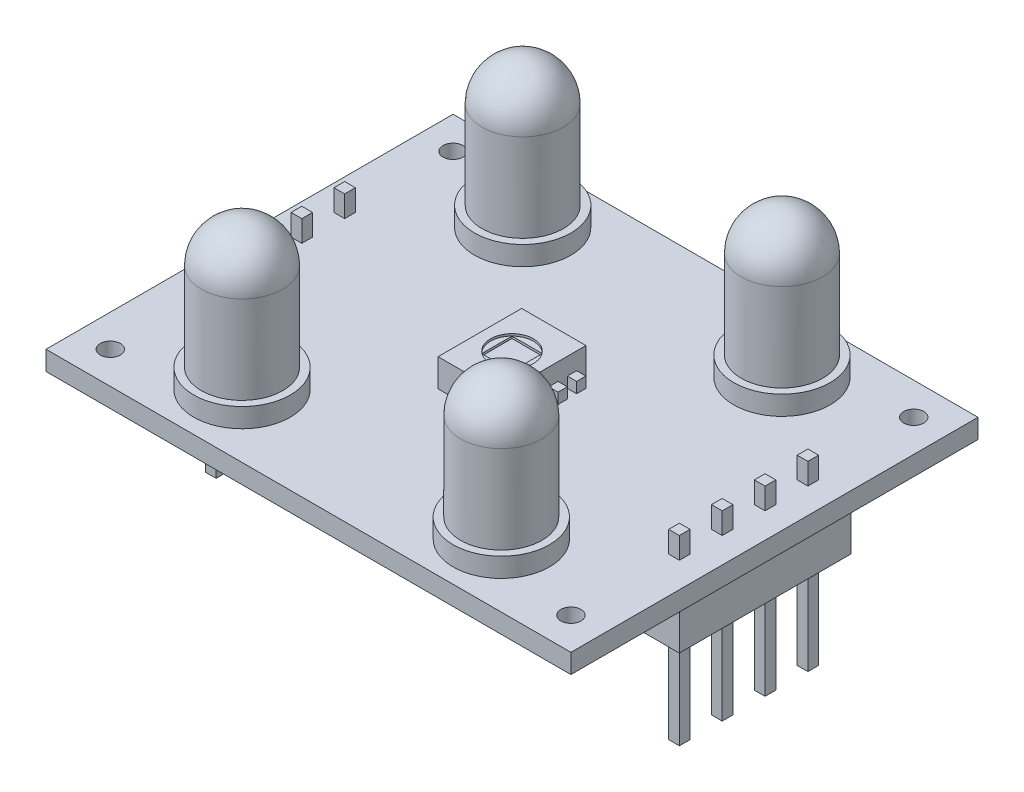
from build123d import *

# Parameters (mm, degrees)
ESQUISSE1_W                     = 31.115
ESQUISSE1_H                     = 24.13
ESQUISSE1_R                     = 0.5953125
BOSS_EXTRU_1_DEPTH              = 0.5715
ESQUISSE2_W                     = 3.81
ESQUISSE2_H                     = 1.651
BOSS_EXTRU_2_DEPTH              = 2.4765
ESQUISSE3_W                     = 0.550333333
ESQUISSE3_H                     = 0.550333334
ESQUISSE3_H_2                   = 0.550333333
BOSS_EXTRU_3_DEPTH              = 0.635
ESQUISSE9_W                     = 2.54
ESQUISSE9_H                     = 10.16
BOSS_EXTRU_6_DEPTH              = 2.667
BOSS_EXTRU_7_START              = -5.08
ESQUISSE10_W                    = 0.635
ESQUISSE10_H                    = 0.635
BOSS_EXTRU_7_DEPTH              = 10.795
ESQUISSE4_R                     = 1.27
ENL_V_MAT_EXTRU_1_DEPTH         = 0.127
ESQUISSE5_W                     = 1.796051224
ESQUISSE5_H                     = 1.796051224
ENL_V_MAT_EXTRU_2_DEPTH         = 0.127
ESQUISSE7_R                     = 2.8575
BOSS_EXTRU_4_DEPTH              = 1.143
ESQUISSE8_R                     = 2.413
BOSS_EXTRU_5_DEPTH              = 7.62
CONG_1_R                        = 2.413
CONG_1_OF_R_P_T_PAR_ESQUISSE1_R = 2.413


with BuildPart() as part:
    # Esquisse1 → Boss.-Extru.1 (new, symmetric)
    with BuildSketch(Plane(origin=(0, 0, 0), x_dir=(1, 0, 0), z_dir=(0, 1, 0))):
        Rectangle(ESQUISSE1_W, ESQUISSE1_H)
        with Locations(Location((-13.6525, 10.16, 0), (0, 0, 270))):
            Circle(ESQUISSE1_R, mode=Mode.SUBTRACT)
        with Locations(Location((13.6525, 10.16, 0), (0, 0, 270))):
            Circle(ESQUISSE1_R, mode=Mode.SUBTRACT)
        with Locations(Location((-13.6525, -10.16, 0), (0, 0, 270))):
            Circle(ESQUISSE1_R, mode=Mode.SUBTRACT)
        with Locations(Location((13.6525, -10.16, 0), (0, 0, 270))):
            Circle(ESQUISSE1_R, mode=Mode.SUBTRACT)
    extrude(amount=BOSS_EXTRU_1_DEPTH, both=True)

    # Esquisse2 → Boss.-Extru.2 (add, symmetric)
    with BuildSketch(Plane.XY):
        with Locations((0, 1.397)):
            Rectangle(ESQUISSE2_W, ESQUISSE2_H)
    extrude(amount=BOSS_EXTRU_2_DEPTH, both=True)

    # Esquisse3 → Boss.-Extru.3 (add)
    with BuildSketch(Plane(origin=(0, 0.5715, 0), x_dir=(1, 0, 0), z_dir=(0, 1, 0))):
        with Locations((2.180166666, 1.651)):
            Rectangle(ESQUISSE3_W, ESQUISSE3_H)
        with Locations((2.180166666, 0.550333334)):
            Rectangle(ESQUISSE3_W, ESQUISSE3_H_2)
        with Locations((2.180166666, -0.550333334)):
            Rectangle(ESQUISSE3_W, ESQUISSE3_H_2)
        with Locations((2.180166666, -1.651)):
            Rectangle(ESQUISSE3_W, ESQUISSE3_H)
    boss_extru_3 = extrude(amount=BOSS_EXTRU_3_DEPTH)

    # Esquisse9 → Boss.-Extru.6 (add)
    with BuildSketch(Plane.XZ.offset(0.5715)):
        with Locations((13.73, 0)):
            Rectangle(ESQUISSE9_W, ESQUISSE9_H)
    boss_extru_6 = extrude(amount=BOSS_EXTRU_6_DEPTH)

    # Esquisse10 → Boss.-Extru.7 (add)
    with BuildSketch(Plane.XZ.offset(3.2385).offset(BOSS_EXTRU_7_START)):
        with Locations((13.73, 3.81)):
            Rectangle(ESQUISSE10_W, ESQUISSE10_H)
        with Locations((13.73, 1.27)):
            Rectangle(ESQUISSE10_W, ESQUISSE10_H)
        with Locations((13.73, -1.27)):
            Rectangle(ESQUISSE10_W, ESQUISSE10_H)
        with Locations((13.73, -3.81)):
            Rectangle(ESQUISSE10_W, ESQUISSE10_H)
    boss_extru_7 = extrude(amount=BOSS_EXTRU_7_DEPTH)

    # Symétrie1: Boss.-Extru.3, Boss.-Extru.7 across plane
    add(boss_extru_3.mirror(Plane(origin=(0, 0, 0), x_dir=(0, 0, 1), z_dir=(1, 0, 0))))
    add(boss_extru_7.mirror(Plane(origin=(0, 0, 0), x_dir=(0, 0, 1), z_dir=(1, 0, 0))))

    # Symétrie2: Boss.-Extru.6 across plane
    add(boss_extru_6.mirror(Plane(origin=(0, 0, 0), x_dir=(0, 0, 1), z_dir=(1, 0, 0))))

    # Esquisse4 → Enlèv. mat.-Extru.1 (cut)
    with BuildSketch(Plane(origin=(0, 2.2225, 0), x_dir=(1, 0, 0), z_dir=(0, 1, 0))):
        with Locations(Location((0, 0, 0), (0, 0, 270))):
            Circle(ESQUISSE4_R)
    extrude(amount=-ENL_V_MAT_EXTRU_1_DEPTH, mode=Mode.SUBTRACT)

    # Esquisse5 → Enlèv. mat.-Extru.2 (cut)
    with BuildSketch(Plane(origin=(0, 2.0955, 0), x_dir=(1, 0, 0), z_dir=(0, 1, 0))):
        Rectangle(ESQUISSE5_W, ESQUISSE5_H)
    extrude(amount=-ENL_V_MAT_EXTRU_2_DEPTH, mode=Mode.SUBTRACT)

    # Esquisse7 → Boss.-Extru.4 (add)
    with BuildSketch(Plane(origin=(0, 0.5715, 0), x_dir=(1, 0, 0), z_dir=(0, 1, 0))):
        with Locations(Location((-7.6835, 8.3185, 0), (0, 0, 90))):
            Circle(ESQUISSE7_R)
    boss_extru_4 = extrude(amount=BOSS_EXTRU_4_DEPTH)

    # Esquisse8 → Boss.-Extru.5 (add)
    with BuildSketch(Plane(origin=(0, 1.7145, 0), x_dir=(1, 0, 0), z_dir=(0, 1, 0))):
        with Locations(Location((-7.6835, 8.3185, 0), (0, 0, 90))):
            Circle(ESQUISSE8_R)
    boss_extru_5 = extrude(amount=BOSS_EXTRU_5_DEPTH)

    # Congé1
    cong_1_edges = [part.edges().sort_by_distance(p)[0] for p in [
        (-7.6835, 9.3345, -5.9055),
    ]]
    fillet(cong_1_edges, radius=CONG_1_R)

    # Répét. par esquisse1: Boss.-Extru.4, Boss.-Extru.5 at 3 more places
    with Locations((15.367, 0, 0), (15.367, 0, 16.637), (0, 0, 16.637)):
        add(boss_extru_4)
        add(boss_extru_5)

    # Congé1 of Répét. par esquisse1
    cong_1_of_r_p_t_par_esquisse1_edges = [part.edges().sort_by_distance(p)[0] for p in [
        (7.6835, 9.3345, -5.9055),
        (7.6835, 9.3345, 10.7315),
        (-7.6835, 9.3345, 10.7315),
    ]]
    fillet(cong_1_of_r_p_t_par_esquisse1_edges, radius=CONG_1_OF_R_P_T_PAR_ESQUISSE1_R)


solid = part.part
